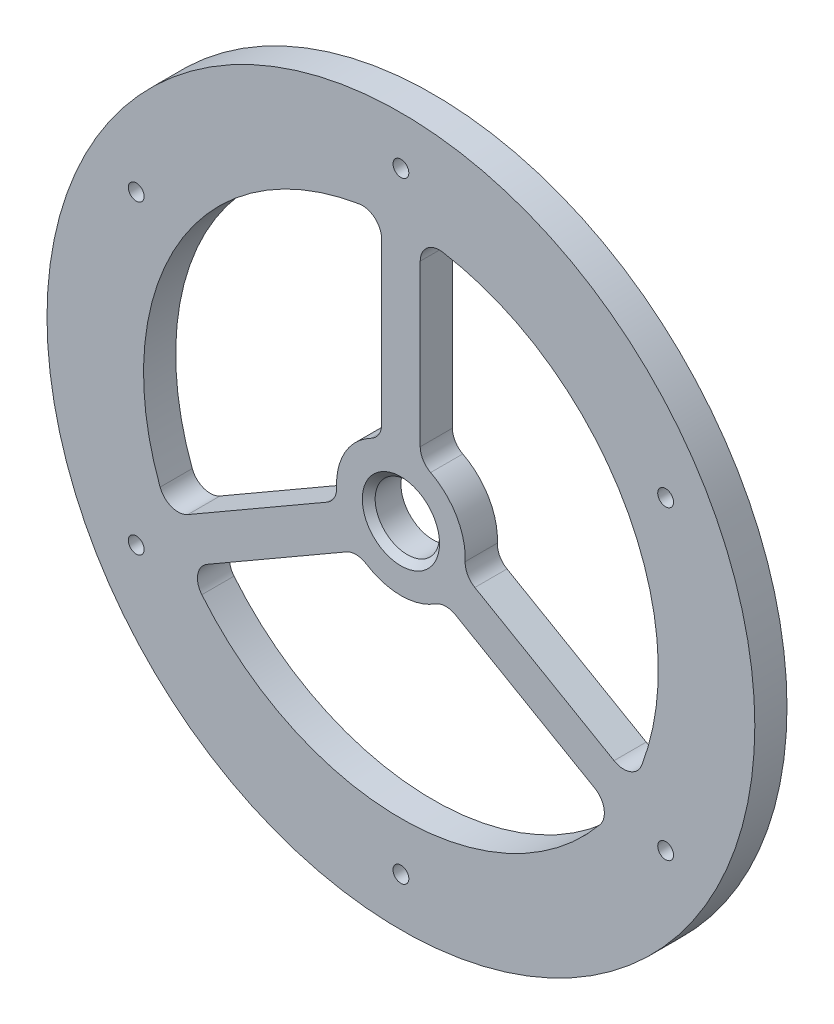
from build123d import *

# Parameters (mm, degrees)
ESQUISSE1_R        = 55
ESQUISSE1_R_2      = 1.227
ESQUISSE1_R_3      = 5
BOSS_EXTRU_1_DEPTH = 5
CONG_1_R           = 3
CHANFREIN1_SIZE    = 1


with BuildPart() as part:
    # Esquisse1 → Boss.-Extru.1 (new body)
    with BuildSketch(Plane.XY):
        Circle(ESQUISSE1_R)
        with Locations((-41.13620668, 23.75)):
            Circle(ESQUISSE1_R_2, mode=Mode.SUBTRACT)
        with Locations((-41.13620668, -23.75)):
            Circle(ESQUISSE1_R_2, mode=Mode.SUBTRACT)
        with Locations((0, -47.5)):
            Circle(ESQUISSE1_R_2, mode=Mode.SUBTRACT)
        with Locations((41.13620668, -23.75)):
            Circle(ESQUISSE1_R_2, mode=Mode.SUBTRACT)
        with Locations((41.13620668, 23.75)):
            Circle(ESQUISSE1_R_2, mode=Mode.SUBTRACT)
        with Locations((0, 47.5)):
            Circle(ESQUISSE1_R_2, mode=Mode.SUBTRACT)
        Circle(ESQUISSE1_R_3, mode=Mode.SUBTRACT)
        with BuildLine():
            ThreePointArc((36.043450899, -17.345594464), (34.641016151, 20), (3, 39.88734135))
            Line((3, 39.88734135), (3, 9.539392014))
            ThreePointArc((3, 9.539392014), (8.660254038, 5), (9.761355821, -2.171619796))
            Line((9.761355821, -2.171619796), (36.043450899, -17.345594464))
        make_face(mode=Mode.SUBTRACT)
        with BuildLine():
            ThreePointArc((-33.043450899, -22.541746887), (0, -40), (33.043450899, -22.541746887))
            Line((33.043450899, -22.541746887), (6.761355821, -7.367772218))
            ThreePointArc((6.761355821, -7.367772218), (0, -10), (-6.761355821, -7.367772218))
            Line((-6.761355821, -7.367772218), (-33.043450899, -22.541746887))
        make_face(mode=Mode.SUBTRACT)
        with BuildLine():
            Line((-3, 9.539392014), (-3, 39.88734135))
            ThreePointArc((-3, 39.88734135), (-34.641016151, 20), (-36.043450899, -17.345594464))
            Line((-36.043450899, -17.345594464), (-9.761355821, -2.171619796))
            ThreePointArc((-9.761355821, -2.171619796), (-8.660254038, 5), (-3, 9.539392014))
        make_face(mode=Mode.SUBTRACT)
    extrude(amount=BOSS_EXTRU_1_DEPTH)

    # Congé1
    cong_1_edges = [part.edges().sort_by_distance(p)[0] for p in [
        (-3, 39.88734135, 2.5),
        (-36.043450899, -17.345594464, 2.5),
        (-9.761355821, -2.171619796, 2.5),
        (-3, 9.539392014, 2.5),
        (33.043450899, -22.541746887, 2.5),
        (6.761355821, -7.367772218, 2.5),
        (-6.761355821, -7.367772218, 2.5),
        (-33.043450899, -22.541746887, 2.5),
        (3, 39.88734135, 2.5),
        (3, 9.539392014, 2.5),
        (9.761355821, -2.171619796, 2.5),
        (36.043450899, -17.345594464, 2.5),
    ]]
    fillet(cong_1_edges, radius=CONG_1_R)

    # Chanfrein1
    chanfrein1_edges = [part.edges().sort_by_distance(p)[0] for p in [
        (-5, 0, 5),
    ]]
    chamfer(chanfrein1_edges, length=CHANFREIN1_SIZE)


solid = part.part
